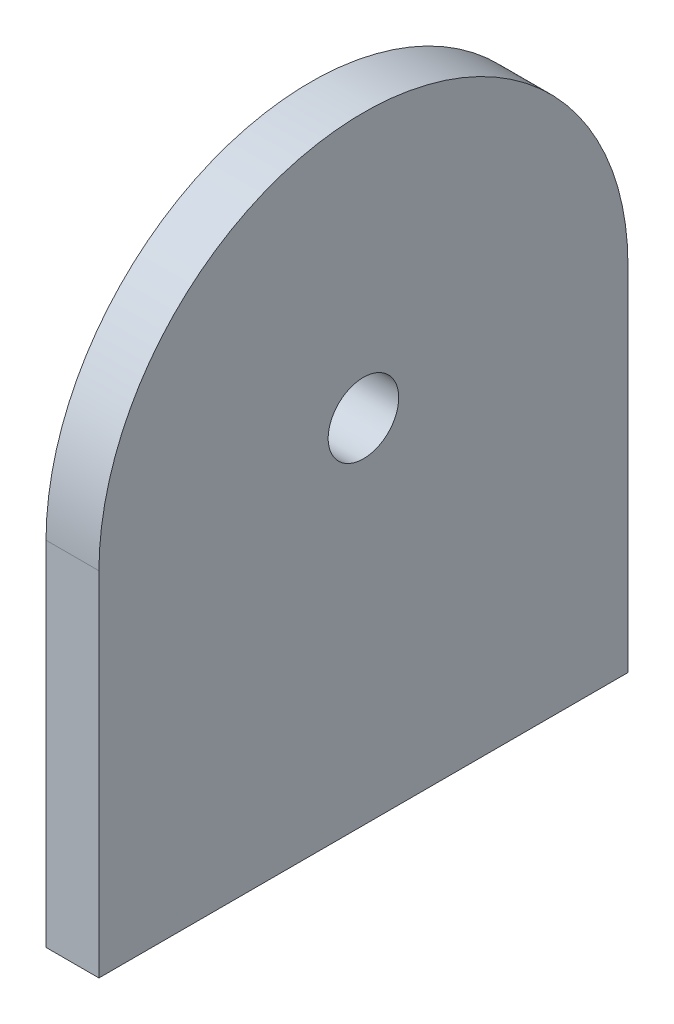
from build123d import *

# Parameters (mm, degrees)
CROQUIS1_R              = 2
SALIENTE_EXTRUIR1_DEPTH = 3


with BuildPart() as part:
    # Croquis1 → Saliente-Extruir1 (new body)
    with BuildSketch(Plane(origin=(0, 0, 0), x_dir=(0, 0, -1), z_dir=(1, 0, 0))):
        with BuildLine():
            Line((0, 20), (0, 0))
            Line((0, 0), (-30, 0))
            Line((-30, 0), (-30, 20))
            ThreePointArc((-30, 20), (-15, 35), (0, 20))
        make_face()
        with Locations((-15, 20)):
            Circle(CROQUIS1_R, mode=Mode.SUBTRACT)
    extrude(amount=SALIENTE_EXTRUIR1_DEPTH)


solid = part.part
